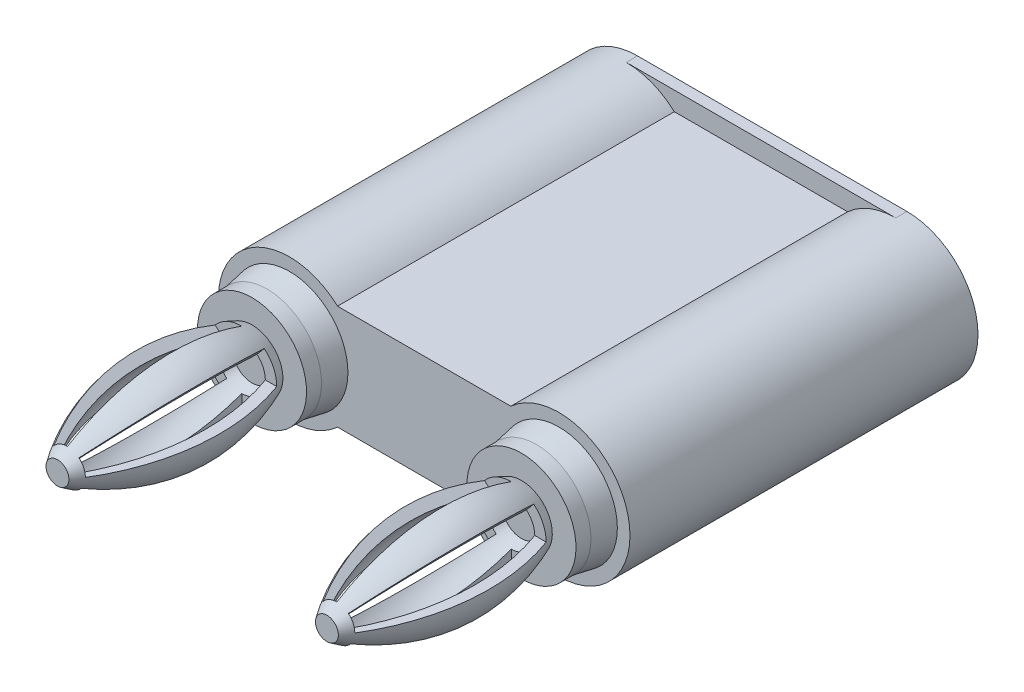
from build123d import *
from build123d.topology import SkipClean

# Parameters (mm, degrees)
BOSS_EXTRUDE1_DEPTH           = 0.762
BOSS_EXTRUDE2_DEPTH           = 22.86
SKETCH3_R                     = 3.96875
BOSS_EXTRUDE3_DEPTH           = 1.524
BOSS_EXTRUDE3_DRAFT           = 10
BOSS_EXTRUDE3_PROFILE_2_DEPTH = 1.524
BOSS_EXTRUDE3_PROFILE_2_DRAFT = 10
CUT_REVOLVE3_ANGLE            = 50
CIRPATTERN1_COUNT             = 4
LPATTERN1_COUNT               = 2
LPATTERN1_PITCH               = 18.288
LPATTERN1_COPY_1_ANGLE        = 50
LPATTERN1_COPY_2_ANGLE        = 50
LPATTERN1_COPY_3_ANGLE        = 50


with BuildPart() as part:
    # Sketch1 → Boss-Extrude1 (new body)
    with BuildSketch(Plane.XY):
        with BuildLine():
            Line((4.826, 0), (23.114, 0))
            ThreePointArc((23.114, 0), (27.94, 4.826), (23.114, 9.652))
            Line((23.114, 9.652), (4.826, 9.652))
            ThreePointArc((4.826, 9.652), (0, 4.826), (4.826, 0))
        make_face()
    extrude(amount=-BOSS_EXTRUDE1_DEPTH)

    # Sketch2 → Boss-Extrude2 (add)
    with SkipClean():  # the faces are left unmerged after this step: merging them gives an invalid solid
        with BuildSketch(Plane.XY):
            with BuildLine():
                Line((8.088689075, 8.382), (19.851310925, 8.382))
                ThreePointArc((19.851310925, 8.382), (27.94, 4.826), (19.851310925, 1.27))
                Line((19.851310925, 1.27), (8.088689075, 1.27))
                ThreePointArc((8.088689075, 1.27), (0, 4.826), (8.088689075, 8.382))
            make_face()
        extrude(amount=BOSS_EXTRUDE2_DEPTH)


with BuildPart() as boss_extrude3_tool:
    # Sketch3 → Boss-Extrude3 (with draft: the straight prism first)
    with BuildSketch(Plane.XY.offset(22.86)):
        with Locations((4.826, 4.826)):
            Circle(SKETCH3_R)
    extrude(amount=BOSS_EXTRUDE3_DEPTH)
    # Boss-Extrude3: the draft: its side faces are tilted about the plane it starts from
    boss_extrude3_sides = [boss_extrude3_tool.faces().sort_by_distance(p)[0] for p in [
        (0.85725, 4.826, 23.622),
    ]]
    draft(boss_extrude3_sides, Plane.XY.offset(22.86), BOSS_EXTRUDE3_DRAFT)


with BuildPart() as part_1:
    add(part.part)

    # Boss-Extrude3: add boss_extrude3_tool
    add(boss_extrude3_tool.part)


with BuildPart() as boss_extrude3_profile_2_tool:
    # Sketch3 → Boss-Extrude3 profile 2 (with draft: the straight prism first)
    with BuildSketch(Plane.XY.offset(22.86)):
        with Locations((23.114, 4.826)):
            Circle(SKETCH3_R)
    extrude(amount=BOSS_EXTRUDE3_PROFILE_2_DEPTH)
    # Boss-Extrude3 profile 2: the draft: its side faces are tilted about the plane it starts from
    boss_extrude3_profile_2_sides = [boss_extrude3_profile_2_tool.faces().sort_by_distance(p)[0] for p in [
        (19.14525, 4.826, 23.622),
    ]]
    draft(boss_extrude3_profile_2_sides, Plane.XY.offset(22.86), BOSS_EXTRUDE3_PROFILE_2_DRAFT)


with BuildPart() as part_2:
    add(part_1.part)

    # Boss-Extrude3 profile 2: add boss_extrude3_profile_2_tool
    add(boss_extrude3_profile_2_tool.part)

    # Sketch4 → Revolve1 (revolve)
    with SkipClean():  # the faces are left unmerged after this step: merging them gives an invalid solid
        with BuildSketch(Plane(origin=(4.826, 0, 0), x_dir=(0, 0, -1), z_dir=(1, 0, 0)), mode=Mode.PRIVATE) as revolve1_sk:
            with BuildLine():
                Line((-24.384, 4.826), (-24.384, 1.125972319))
                Line((-24.384, 1.125972319), (-25.4, 1.125972319))
                Line((-25.4, 1.125972319), (-25.4, 2.73266772))
                ThreePointArc((-25.4, 2.73266772), (-32.174307479, 1.680893342), (-38.608, 4.048396608))
                Line((-38.608, 4.048396608), (-38.608, 4.826))
                Line((-38.608, 4.826), (-24.384, 4.826))
            make_face()
        revolve1 = revolve(revolve1_sk.sketch.rotate(Axis((4.826, 4.826, 24.384), (0, 0, 1)), 180), axis=Axis((4.826, 4.826, 24.384), (0, 0, 1)))

    # Sketch6 → Cut-Revolve2 (revolve, cut)
    with SkipClean():  # the faces are left unmerged after this step: merging them gives an invalid solid
        with BuildSketch(Plane(origin=(4.826, 0, 0), x_dir=(0, 0, -1), z_dir=(1, 0, 0)), mode=Mode.PRIVATE) as cut_revolve2_sk:
            with BuildLine():
                Line((-38.162876682, 4.826), (-38.162876682, 4.231826558))
                ThreePointArc((-38.162876682, 4.231826558), (-31.866366293, 2.379117304), (-25.4, 3.503697948))
                Line((-25.4, 3.503697948), (-25.4, 4.826))
                Line((-25.4, 4.826), (-38.162876682, 4.826))
            make_face()
        cut_revolve2 = revolve(cut_revolve2_sk.sketch.rotate(Axis((4.826, 4.826, 25.4), (0, 0, 1)), 180), axis=Axis((4.826, 4.826, 25.4), (0, 0, 1)), mode=Mode.SUBTRACT)

    # Sketch7 → Cut-Revolve3 (revolve, cut)
    with SkipClean():  # the faces are left unmerged after this step: merging them gives an invalid solid
        with BuildSketch(Plane(origin=(4.826, 0, 0), x_dir=(0, 0, -1), z_dir=(1, 0, 0))):
            Polygon((-26.092804741, 4.826), (-26.092804741, 1.351556831), (-37.929911839, 1.576668218), (-37.929911839, 4.826), align=None)
        cut_revolve3 = revolve(axis=Axis((4.826, 4.826, 25.4), (0, 0, 1)), revolution_arc=CUT_REVOLVE3_ANGLE, mode=Mode.SUBTRACT)

    # CirPattern1: Cut-Revolve3 ×4 about axis
    with SkipClean():  # the faces are left unmerged after this step: merging them gives an invalid solid
        cirpattern1_axis = Axis((4.826, 4.826, 38.608), (0, 0, -1))
        for i in range(1, CIRPATTERN1_COUNT):
            add(cut_revolve3.rotate(cirpattern1_axis, i * 360 / CIRPATTERN1_COUNT), mode=Mode.SUBTRACT)

    # LPattern1: Revolve1, Cut-Revolve2, Cut-Revolve3 ×2
    with SkipClean():  # the faces are left unmerged after this step: merging them gives an invalid solid
        with Locations(*[(i * LPATTERN1_PITCH, 0, 0) for i in range(1, LPATTERN1_COUNT)]):
            add(revolve1)
            add(cut_revolve2, mode=Mode.SUBTRACT)
            add(cut_revolve3, mode=Mode.SUBTRACT)

    # LPattern1 copy 1 sketch → LPattern1 copy 1 (revolve, cut)
    with SkipClean():  # the faces are left unmerged after this step: merging them gives an invalid solid
        with BuildSketch(Plane(origin=(18.288, 4.826, 0), x_dir=(0, 0, -1), z_dir=(0, -1, 0))):
            Polygon((-26.092804741, 4.826), (-26.092804741, 1.351556831), (-37.929911839, 1.576668218), (-37.929911839, 4.826), align=None)
        revolve(axis=Axis((23.114, 4.826, 25.4), (0, 0, 1)), revolution_arc=LPATTERN1_COPY_1_ANGLE, mode=Mode.SUBTRACT)

    # LPattern1 copy 2 sketch → LPattern1 copy 2 (revolve, cut)
    with SkipClean():  # the faces are left unmerged after this step: merging them gives an invalid solid
        with BuildSketch(Plane(origin=(23.114, 9.652, 0), x_dir=(0, 0, -1), z_dir=(-1, 0, 0))):
            Polygon((-26.092804741, 4.826), (-26.092804741, 1.351556831), (-37.929911839, 1.576668218), (-37.929911839, 4.826), align=None)
        revolve(axis=Axis((23.114, 4.826, 25.4), (0, 0, 1)), revolution_arc=LPATTERN1_COPY_2_ANGLE, mode=Mode.SUBTRACT)

    # LPattern1 copy 3 sketch → LPattern1 copy 3 (revolve, cut)
    with SkipClean():  # the faces are left unmerged after this step: merging them gives an invalid solid
        with BuildSketch(Plane(origin=(27.94, 4.826, 0), x_dir=(0, 0, -1), z_dir=(0, 1, 0))):
            Polygon((-26.092804741, 4.826), (-26.092804741, 1.351556831), (-37.929911839, 1.576668218), (-37.929911839, 4.826), align=None)
        revolve(axis=Axis((23.114, 4.826, 25.4), (0, 0, 1)), revolution_arc=LPATTERN1_COPY_3_ANGLE, mode=Mode.SUBTRACT)


solid = part_2.part
